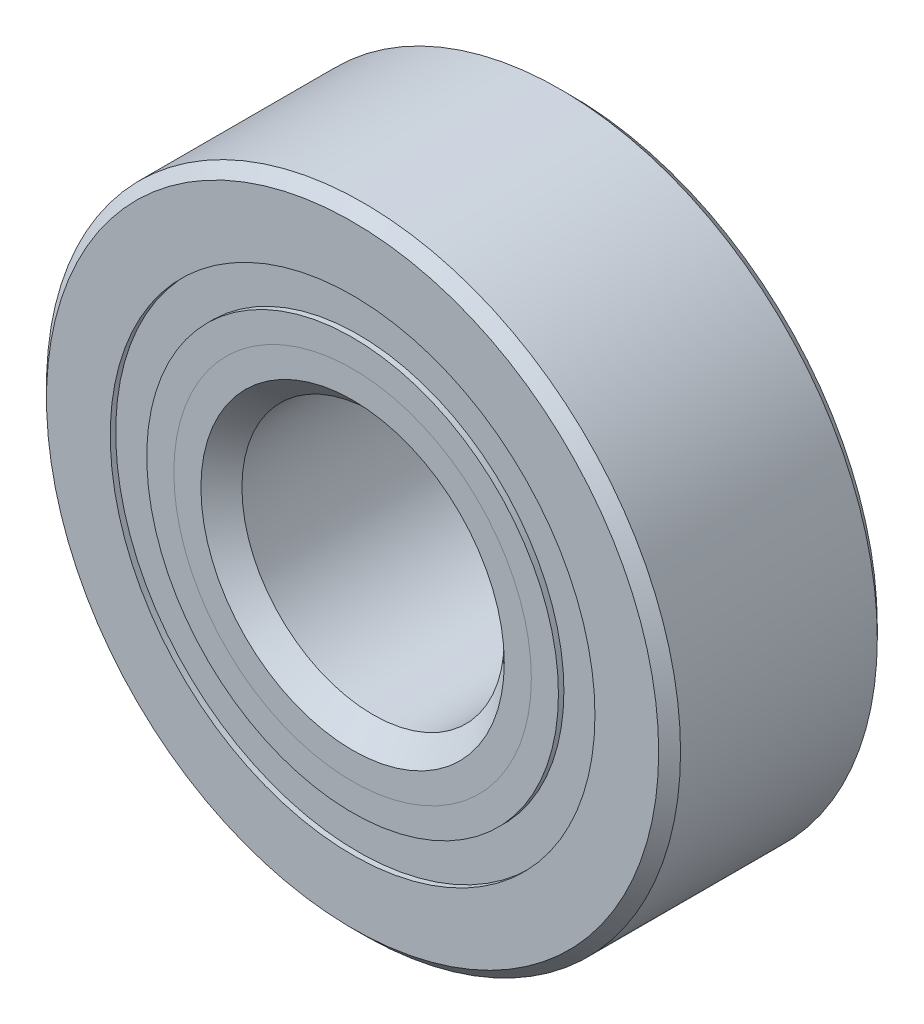
from build123d import *

# Parameters (mm, degrees)
CIRPATTERN1_COUNT = 12
SKETCH5_W         = 1.885967402
SKETCH5_H         = 1.325824176


with BuildPart() as part:
    # Sketch1 → Revolve1 (revolve)
    with BuildSketch(Plane(origin=(0, 0, 0), x_dir=(0, 0, -1), z_dir=(1, 0, 0))):
        with BuildLine():
            Line((3.571875, 11.509375), (-3.571875, 11.509375))
            Line((-3.571875, 11.509375), (-3.96875, 11.1125))
            Line((-3.96875, 11.1125), (-3.96875, 8.798849588))
            Line((-3.96875, 8.798849588), (-1.763888889, 8.798849588))
            ThreePointArc((-1.763888889, 8.798849588), (0, 10.020282598), (1.763888889, 8.798849588))
            Line((1.763888889, 8.798849588), (3.96875, 8.798849588))
            Line((3.96875, 8.798849588), (3.96875, 11.1125))
            Line((3.96875, 11.1125), (3.571875, 11.509375))
        make_face()
    revolve(axis=Axis((0, 0, 3.96875), (0, 0, -1)))


with BuildPart() as body_2:
    # Sketch2 → Revolve2 (revolve)
    with BuildSketch(Plane(origin=(0, 0, 0), x_dir=(0, 0, -1), z_dir=(1, 0, 0))):
        with BuildLine():
            Line((-3.96875, 7.473025412), (-1.763888889, 7.473025412))
            ThreePointArc((-1.763888889, 7.473025412), (-1.072753771, 6.586758428), (0, 6.251592402))
            Line((0, 6.251592402), (0, 5.507046201))
            Line((0, 5.507046201), (-2.985760394, 5.507046201))
            Line((-2.985760394, 5.507046201), (-3.96875, 6.490035807))
            Line((-3.96875, 6.490035807), (-3.96875, 7.473025412))
        make_face()
    revolve(axis=Axis((0, 0, 3.96875), (0, 0, -1)))


with BuildPart() as body_3:
    # Sketch3 → Revolve3 (revolve)
    with BuildSketch(Plane(origin=(0, 0, 0), x_dir=(0, 0, -1), z_dir=(1, 0, 0))):
        with BuildLine():
            Line((-3.96875, 6.490035807), (-2.985760394, 5.507046201))
            Line((-2.985760394, 5.507046201), (0, 5.507046201))
            Line((0, 5.507046201), (0, 6.251592402))
            ThreePointArc((0, 6.251592402), (1.072753771, 6.586758428), (1.763888889, 7.473025412))
            Line((1.763888889, 7.473025412), (3.96875, 7.473025412))
            Line((3.96875, 7.473025412), (3.96875, 5.159375))
            Line((3.96875, 5.159375), (3.571875, 4.7625))
            Line((3.571875, 4.7625), (-3.224203799, 4.7625))
            Line((-3.224203799, 4.7625), (-3.96875, 5.507046201))
            Line((-3.96875, 5.507046201), (-3.96875, 6.490035807))
        make_face()
    revolve(axis=Axis((0, 0, 3.96875), (0, 0, -1)))


with BuildPart() as body_4:
    # Sketch4 → Revolve4 (revolve)
    with BuildSketch(Plane(origin=(0, 0, 0), x_dir=(0, 0, -1), z_dir=(1, 0, 0))):
        with BuildLine():
            Line((-1.884345098, 8.1359375), (1.884345098, 8.1359375))
            ThreePointArc((1.884345098, 8.1359375), (0, 10.020282598), (-1.884345098, 8.1359375))
        make_face()
    revolve(axis=Axis((0, 8.1359375, 1.884345098), (0, 0, -1)))


with BuildPart() as cirpattern1_1:
    # CirPattern1: pattern copy
    add(body_4.part.rotate(Axis((0, 0, -3.96875), (0, 0, 1)), 1 * 360 / CIRPATTERN1_COUNT))


with BuildPart() as cirpattern1_2:
    # CirPattern1: pattern copy
    add(body_4.part.rotate(Axis((0, 0, -3.96875), (0, 0, 1)), 2 * 360 / CIRPATTERN1_COUNT))


with BuildPart() as cirpattern1_3:
    # CirPattern1: pattern copy
    add(body_4.part.rotate(Axis((0, 0, -3.96875), (0, 0, 1)), 3 * 360 / CIRPATTERN1_COUNT))


with BuildPart() as cirpattern1_4:
    # CirPattern1: pattern copy
    add(body_4.part.rotate(Axis((0, 0, -3.96875), (0, 0, 1)), 4 * 360 / CIRPATTERN1_COUNT))


with BuildPart() as cirpattern1_5:
    # CirPattern1: pattern copy
    add(body_4.part.rotate(Axis((0, 0, -3.96875), (0, 0, 1)), 5 * 360 / CIRPATTERN1_COUNT))


with BuildPart() as cirpattern1_6:
    # CirPattern1: pattern copy
    add(body_4.part.rotate(Axis((0, 0, -3.96875), (0, 0, 1)), 6 * 360 / CIRPATTERN1_COUNT))


with BuildPart() as cirpattern1_7:
    # CirPattern1: pattern copy
    add(body_4.part.rotate(Axis((0, 0, -3.96875), (0, 0, 1)), 7 * 360 / CIRPATTERN1_COUNT))


with BuildPart() as cirpattern1_8:
    # CirPattern1: pattern copy
    add(body_4.part.rotate(Axis((0, 0, -3.96875), (0, 0, 1)), 8 * 360 / CIRPATTERN1_COUNT))


with BuildPart() as cirpattern1_9:
    # CirPattern1: pattern copy
    add(body_4.part.rotate(Axis((0, 0, -3.96875), (0, 0, 1)), 9 * 360 / CIRPATTERN1_COUNT))


with BuildPart() as cirpattern1_10:
    # CirPattern1: pattern copy
    add(body_4.part.rotate(Axis((0, 0, -3.96875), (0, 0, 1)), 10 * 360 / CIRPATTERN1_COUNT))


with BuildPart() as cirpattern1_11:
    # CirPattern1: pattern copy
    add(body_4.part.rotate(Axis((0, 0, -3.96875), (0, 0, 1)), 11 * 360 / CIRPATTERN1_COUNT))


with BuildPart() as body_16:
    # Sketch5 → Revolve5 (revolve)
    with BuildSketch(Plane(origin=(0, 0, 0), x_dir=(0, 0, -1), z_dir=(1, 0, 0))):
        with Locations((-2.827328799, 8.1359375)):
            Rectangle(SKETCH5_W, SKETCH5_H)
        with Locations((2.827328799, 8.1359375)):
            Rectangle(SKETCH5_W, SKETCH5_H)
    revolve(axis=Axis((0, 0, 3.96875), (0, 0, -1)))


solid = Compound([part.part, body_2.part, body_3.part, body_4.part, cirpattern1_1.part, cirpattern1_2.part, cirpattern1_3.part, cirpattern1_4.part, cirpattern1_5.part, cirpattern1_6.part, cirpattern1_7.part, cirpattern1_8.part, cirpattern1_9.part, cirpattern1_10.part, cirpattern1_11.part, body_16.part])
